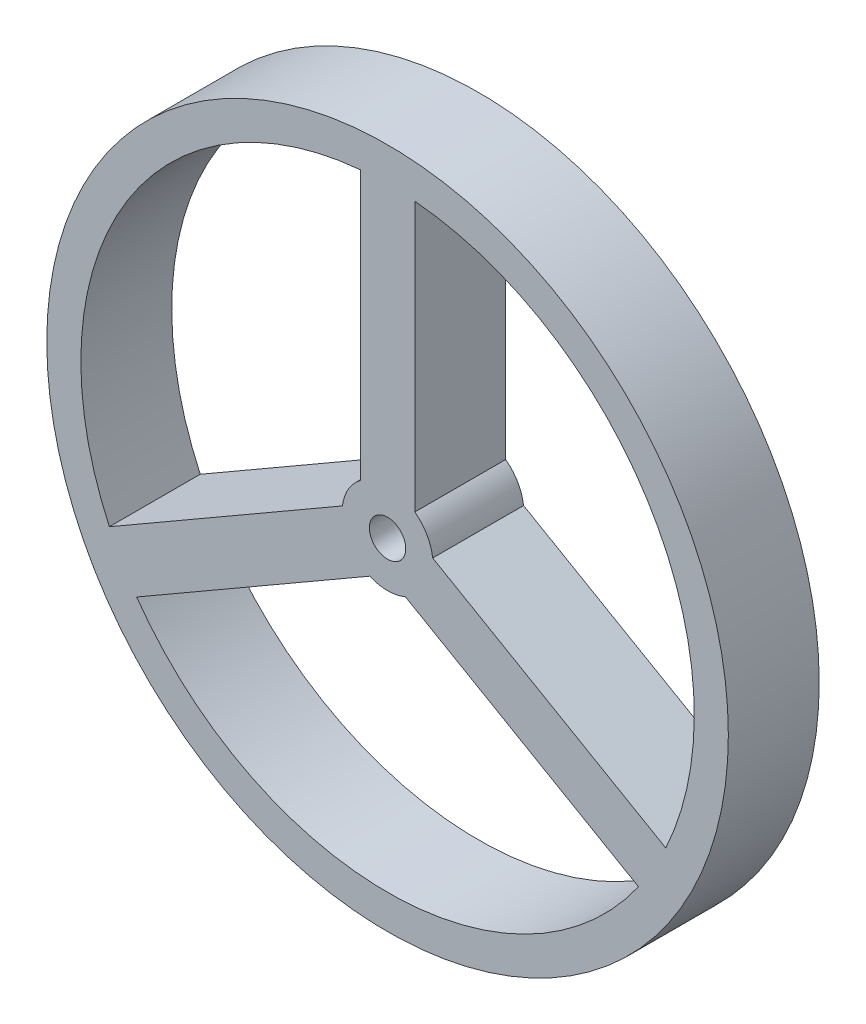
from build123d import *

# Parameters (mm, degrees)
SKETCH1_R           = 7.5
SKETCH1_R_2         = 0.4
BOSS_EXTRUDE1_DEPTH = 2


with BuildPart() as part:
    # Sketch1 → Boss-Extrude1 (new body)
    with BuildSketch(Plane.XY):
        Circle(SKETCH1_R)
        with BuildLine():
            Line((-0.6, 6.723280449), (-0.6, 0.8))
            ThreePointArc((-0.6, 0.8), (-0.866025404, 0.5), (-0.992820323, 0.119615242))
            Line((-0.992820323, 0.119615242), (-6.122531666, -2.842024982))
            ThreePointArc((-6.122531666, -2.842024982), (-5.845671476, 3.375), (-0.6, 6.723280449))
        make_face(mode=Mode.SUBTRACT)
        with BuildLine():
            Line((-5.522531666, -3.881255467), (-0.392820323, -0.919615242))
            ThreePointArc((-0.392820323, -0.919615242), (0, -1), (0.392820323, -0.919615242))
            Line((0.392820323, -0.919615242), (5.522531666, -3.881255467))
            ThreePointArc((5.522531666, -3.881255467), (0, -6.75), (-5.522531666, -3.881255467))
        make_face(mode=Mode.SUBTRACT)
        with BuildLine():
            Line((6.122531666, -2.842024982), (0.992820323, 0.119615242))
            ThreePointArc((0.992820323, 0.119615242), (0.866025404, 0.5), (0.6, 0.8))
            Line((0.6, 0.8), (0.6, 6.723280449))
            ThreePointArc((0.6, 6.723280449), (5.845671476, 3.375), (6.122531666, -2.842024982))
        make_face(mode=Mode.SUBTRACT)
        Circle(SKETCH1_R_2, mode=Mode.SUBTRACT)
    extrude(amount=BOSS_EXTRUDE1_DEPTH)


solid = part.part
